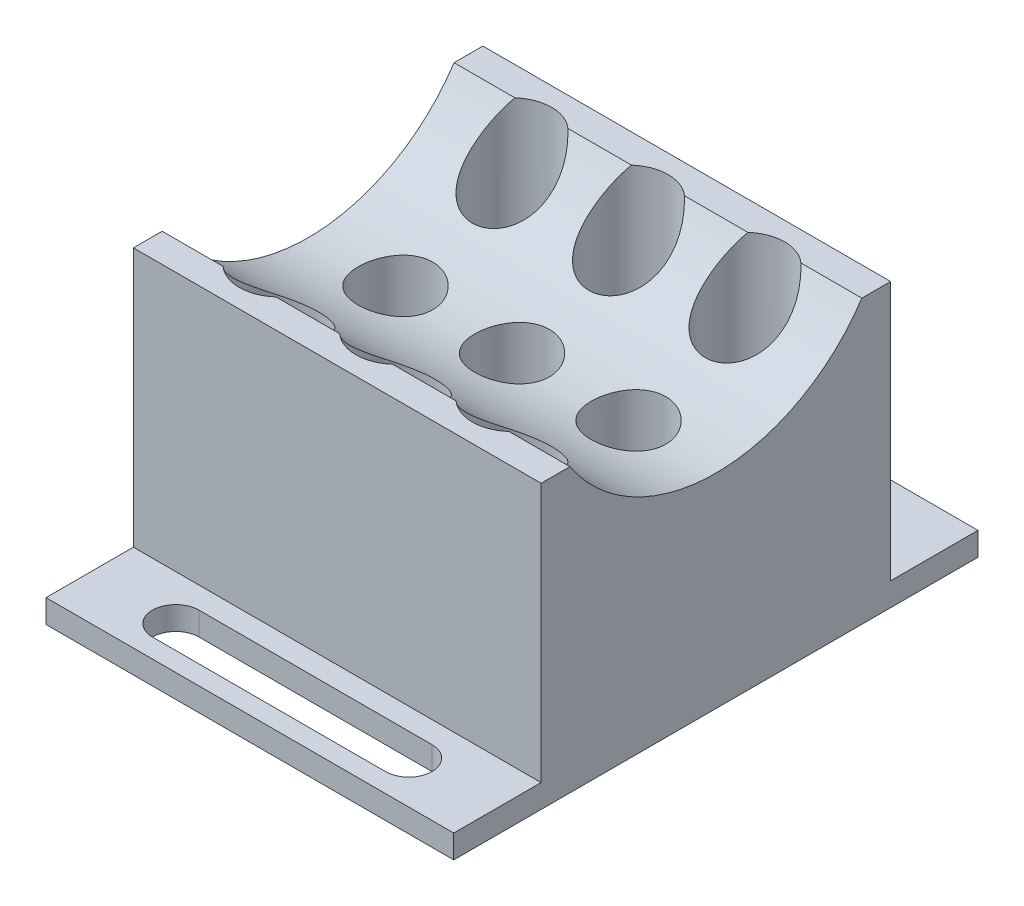
from build123d import *

# Parameters (mm, degrees)
SKETCH8_W                       = 35
SKETCH8_H                       = 30
BOSS_EXTRUDE7_DEPTH             = 80
SKETCH10_R                      = 15
CUT_EXTRUDE3_DEPTH              = 18.5
CUT_EXTRUDE3_DEPTH_BACK         = 18.5
SKETCH11_W                      = 38.336381606
SKETCH11_H                      = 16.50007926
CUT_EXTRUDE4_DEPTH              = 18.5
CUT_EXTRUDE4_DEPTH_BACK         = 18.5
SKETCH12_W                      = 33.824881692
SKETCH12_H                      = 7.5
CUT_EXTRUDE5_DEPTH              = 18.5
CUT_EXTRUDE5_DEPTH_BACK         = 18.5
SKETCH13_W                      = 45.541829225
SKETCH13_H                      = 41.48776408
CUT_EXTRUDE6_DEPTH              = 18.5
CUT_EXTRUDE6_DEPTH_BACK         = 18.5
SKETCH15_W                      = 35
SKETCH15_H                      = 7.5
BOSS_EXTRUDE9_DEPTH             = 2
CUT_EXTRUDE7_DEPTH              = 2
SKETCH18_R                      = 3.2
CUT_EXTRUDE10_DEPTH             = 7.74996037
CUT_EXTRUDE10_DEPTH_BACK        = 6.4
CUT_EXTRUDE11_REACH             = 8.75
SKETCH19_R                      = 3.4
CUT_EXTRUDE11_DIRECTION_2_DEPTH = 4.9


with BuildPart() as part:
    # Sketch8 → Boss-Extrude7 (new body)
    with BuildSketch(Plane(origin=(0, 0, 0), x_dir=(1, 0, 0), z_dir=(0, 1, 0))):
        Rectangle(SKETCH8_W, SKETCH8_H)
    extrude(amount=BOSS_EXTRUDE7_DEPTH)

    # Sketch10 → Cut-Extrude3 (cut, two sides)
    with BuildSketch(Plane(origin=(0, 0, 0), x_dir=(0, 0, -1), z_dir=(1, 0, 0))) as cut_extrude3_sk:
        with Locations((0, 40)):
            Circle(SKETCH10_R)
    extrude(amount=CUT_EXTRUDE3_DEPTH, mode=Mode.SUBTRACT)
    extrude(cut_extrude3_sk.sketch, amount=-CUT_EXTRUDE3_DEPTH_BACK, mode=Mode.SUBTRACT)

    # Sketch11 → Cut-Extrude4 (cut, two sides)
    with BuildSketch(Plane(origin=(0, 0, 0), x_dir=(0, 0, -1), z_dir=(1, 0, 0))) as cut_extrude4_sk:
        with Locations((0, 40)):
            Rectangle(SKETCH11_W, SKETCH11_H)
    extrude(amount=CUT_EXTRUDE4_DEPTH, mode=Mode.SUBTRACT)
    extrude(cut_extrude4_sk.sketch, amount=-CUT_EXTRUDE4_DEPTH_BACK, mode=Mode.SUBTRACT)

    # Sketch12 → Cut-Extrude5 (cut, two sides)
    with BuildSketch(Plane(origin=(0, 0, 0), x_dir=(0, 0, -1), z_dir=(1, 0, 0))) as cut_extrude5_sk:
        with Locations((0.439040256, 3.75)):
            Rectangle(SKETCH12_W, SKETCH12_H)
    extrude(amount=CUT_EXTRUDE5_DEPTH, mode=Mode.SUBTRACT)
    extrude(cut_extrude5_sk.sketch, amount=-CUT_EXTRUDE5_DEPTH_BACK, mode=Mode.SUBTRACT)

    # Sketch13 → Cut-Extrude6 (cut, two sides)
    with BuildSketch(Plane(origin=(0, 0, 0), x_dir=(0, 0, -1), z_dir=(1, 0, 0))) as cut_extrude6_sk:
        with Locations((-6.569234617, 60.808180877)):
            Rectangle(SKETCH13_W, SKETCH13_H)
    extrude(amount=CUT_EXTRUDE6_DEPTH, mode=Mode.SUBTRACT)
    extrude(cut_extrude6_sk.sketch, amount=-CUT_EXTRUDE6_DEPTH_BACK, mode=Mode.SUBTRACT)

    # Sketch15 → Boss-Extrude9 (add)
    with BuildSketch(Plane(origin=(0, 7.5, 0), x_dir=(-1, 0, 0), z_dir=(0, -1, 0))):
        with Locations((0, -18.75)):
            Rectangle(SKETCH15_W, SKETCH15_H)
        with Locations((0, 18.75)):
            Rectangle(SKETCH15_W, SKETCH15_H)
    extrude(amount=-BOSS_EXTRUDE9_DEPTH)

    # Sketch16 → Cut-Extrude7 (cut)
    with BuildSketch(Plane(origin=(0, 7.5, 0), x_dir=(-1, 0, 0), z_dir=(0, -1, 0))):
        with BuildLine():
            Line((10, -20.863517543), (-10, -20.863517543))
            ThreePointArc((-10, -20.863517543), (-12, -18.863517543), (-10, -16.863517543))
            Line((-10, -16.863517543), (10, -16.863517543))
            ThreePointArc((10, -16.863517543), (12, -18.863517543), (10, -20.863517543))
        make_face()
        with BuildLine():
            Line((10, 16.803450623), (-10, 16.803450623))
            ThreePointArc((-10, 16.803450623), (-12, 18.803450623), (-10, 20.803450623))
            Line((-10, 20.803450623), (10, 20.803450623))
            ThreePointArc((10, 20.803450623), (12, 18.803450623), (10, 16.803450623))
        make_face()
    extrude(amount=-CUT_EXTRUDE7_DEPTH, mode=Mode.SUBTRACT)

    # Sketch18 → Cut-Extrude10 (cut, two sides)
    with BuildSketch(Plane(origin=(0, 25, 0), x_dir=(1, 0, 0), z_dir=(0, 1, 0))) as cut_extrude10_sk:
        Circle(SKETCH18_R)
        with Locations((10, 0)):
            Circle(SKETCH18_R)
        with Locations((-10, 0)):
            Circle(SKETCH18_R)
    extrude(amount=CUT_EXTRUDE10_DEPTH, mode=Mode.SUBTRACT)
    extrude(cut_extrude10_sk.sketch, amount=-CUT_EXTRUDE10_DEPTH_BACK, mode=Mode.SUBTRACT)

    # Sketch19 → Cut-Extrude11 (cut, up to next)
    with BuildSketch(Plane(origin=(0, 25, 0), x_dir=(1, 0, 0), z_dir=(0, 1, 0)), mode=Mode.PRIVATE) as cut_extrude11_sk1:
        with Locations((-10, -10)):
            Circle(SKETCH19_R)
    cut_extrude11_tool1 = extrude(cut_extrude11_sk1.sketch, amount=CUT_EXTRUDE11_REACH, mode=Mode.PRIVATE) & part.part
    add(cut_extrude11_tool1.solids().sort_by_distance((-10, 25, 10))[0], mode=Mode.SUBTRACT)
    # Sketch19 → Cut-Extrude11 (cut, up to next)
    with BuildSketch(Plane(origin=(0, 25, 0), x_dir=(1, 0, 0), z_dir=(0, 1, 0)), mode=Mode.PRIVATE) as cut_extrude11_sk2:
        with Locations((0, -10)):
            Circle(SKETCH19_R)
    cut_extrude11_tool2 = extrude(cut_extrude11_sk2.sketch, amount=CUT_EXTRUDE11_REACH, mode=Mode.PRIVATE) & part.part
    add(cut_extrude11_tool2.solids().sort_by_distance((0, 25, 10))[0], mode=Mode.SUBTRACT)
    # Sketch19 → Cut-Extrude11 (cut, up to next)
    with BuildSketch(Plane(origin=(0, 25, 0), x_dir=(1, 0, 0), z_dir=(0, 1, 0)), mode=Mode.PRIVATE) as cut_extrude11_sk3:
        with Locations((10, -10)):
            Circle(SKETCH19_R)
    cut_extrude11_tool3 = extrude(cut_extrude11_sk3.sketch, amount=CUT_EXTRUDE11_REACH, mode=Mode.PRIVATE) & part.part
    add(cut_extrude11_tool3.solids().sort_by_distance((10, 25, 10))[0], mode=Mode.SUBTRACT)
    # Sketch19 → Cut-Extrude11 (cut, up to next)
    with BuildSketch(Plane(origin=(0, 25, 0), x_dir=(1, 0, 0), z_dir=(0, 1, 0)), mode=Mode.PRIVATE) as cut_extrude11_sk4:
        with Locations((-10, 10)):
            Circle(SKETCH19_R)
    cut_extrude11_tool4 = extrude(cut_extrude11_sk4.sketch, amount=CUT_EXTRUDE11_REACH, mode=Mode.PRIVATE) & part.part
    add(cut_extrude11_tool4.solids().sort_by_distance((-10, 25, -10))[0], mode=Mode.SUBTRACT)
    # Sketch19 → Cut-Extrude11 (cut, up to next)
    with BuildSketch(Plane(origin=(0, 25, 0), x_dir=(1, 0, 0), z_dir=(0, 1, 0)), mode=Mode.PRIVATE) as cut_extrude11_sk5:
        with Locations((0, 10)):
            Circle(SKETCH19_R)
    cut_extrude11_tool5 = extrude(cut_extrude11_sk5.sketch, amount=CUT_EXTRUDE11_REACH, mode=Mode.PRIVATE) & part.part
    add(cut_extrude11_tool5.solids().sort_by_distance((0, 25, -10))[0], mode=Mode.SUBTRACT)
    # Sketch19 → Cut-Extrude11 (cut, up to next)
    with BuildSketch(Plane(origin=(0, 25, 0), x_dir=(1, 0, 0), z_dir=(0, 1, 0)), mode=Mode.PRIVATE) as cut_extrude11_sk6:
        with Locations((10, 10)):
            Circle(SKETCH19_R)
    cut_extrude11_tool6 = extrude(cut_extrude11_sk6.sketch, amount=CUT_EXTRUDE11_REACH, mode=Mode.PRIVATE) & part.part
    add(cut_extrude11_tool6.solids().sort_by_distance((10, 25, -10))[0], mode=Mode.SUBTRACT)

    # Sketch19 → Cut-Extrude11 direction 2 (cut)
    with BuildSketch(Plane(origin=(0, 25, 0), x_dir=(1, 0, 0), z_dir=(0, 1, 0))):
        with Locations((-10, -10)):
            Circle(SKETCH19_R)
        with Locations((0, -10)):
            Circle(SKETCH19_R)
        with Locations((10, -10)):
            Circle(SKETCH19_R)
        with Locations((-10, 10)):
            Circle(SKETCH19_R)
        with Locations((0, 10)):
            Circle(SKETCH19_R)
        with Locations((10, 10)):
            Circle(SKETCH19_R)
    extrude(amount=-CUT_EXTRUDE11_DIRECTION_2_DEPTH, mode=Mode.SUBTRACT)


solid = part.part
